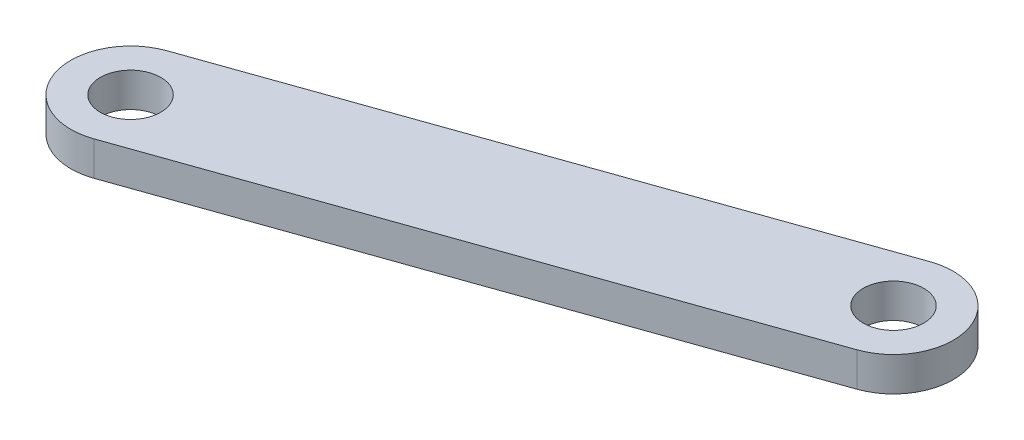
from build123d import *

# Parameters (mm, degrees)
BOSS_EXTRUDE1_DEPTH = 1.27
CUT_EXTRUDE1_REACH  = 4.54
SKETCH3_R           = 2.2479


with BuildPart() as part:
    # Sketch2 → Boss-Extrude1 (new body, symmetric)
    with BuildSketch(Plane(origin=(0, 0, 0), x_dir=(1, 0, 0), z_dir=(0, 1, 0))):
        with BuildLine():
            ThreePointArc((-6.507736872, 31.666944674), (-0.838000837, 28.952143892), (-3.552801619, 23.282407856))
            Line((-3.552801619, 23.282407856), (-45.475485708, 8.507731591))
            ThreePointArc((-45.475485708, 8.507731591), (-51.145221744, 11.222532373), (-48.430420961, 16.892268409))
            Line((-48.430420961, 16.892268409), (-6.507736872, 31.666944674))
        make_face()
    extrude(amount=BOSS_EXTRUDE1_DEPTH, both=True)

    # Sketch3 → Cut-Extrude1 (cut, up to next)
    with BuildSketch(Plane(origin=(0, 1.27, 0), x_dir=(1, 0, 0), z_dir=(0, 1, 0)), mode=Mode.PRIVATE) as cut_extrude1_sk1:
        with Locations((-5.030269245, 27.474676265)):
            Circle(SKETCH3_R)
    cut_extrude1_tool1 = extrude(cut_extrude1_sk1.sketch, amount=-CUT_EXTRUDE1_REACH, mode=Mode.PRIVATE) & part.part
    add(cut_extrude1_tool1.solids().sort_by_distance((-5.030269, 1.27, -27.474676))[0], mode=Mode.SUBTRACT)
    # Sketch3 → Cut-Extrude1 (cut, up to next)
    with BuildSketch(Plane(origin=(0, 1.27, 0), x_dir=(1, 0, 0), z_dir=(0, 1, 0)), mode=Mode.PRIVATE) as cut_extrude1_sk2:
        with Locations((-46.952953335, 12.7)):
            Circle(SKETCH3_R)
    cut_extrude1_tool2 = extrude(cut_extrude1_sk2.sketch, amount=-CUT_EXTRUDE1_REACH, mode=Mode.PRIVATE) & part.part
    add(cut_extrude1_tool2.solids().sort_by_distance((-46.952953, 1.27, -12.7))[0], mode=Mode.SUBTRACT)


solid = part.part
